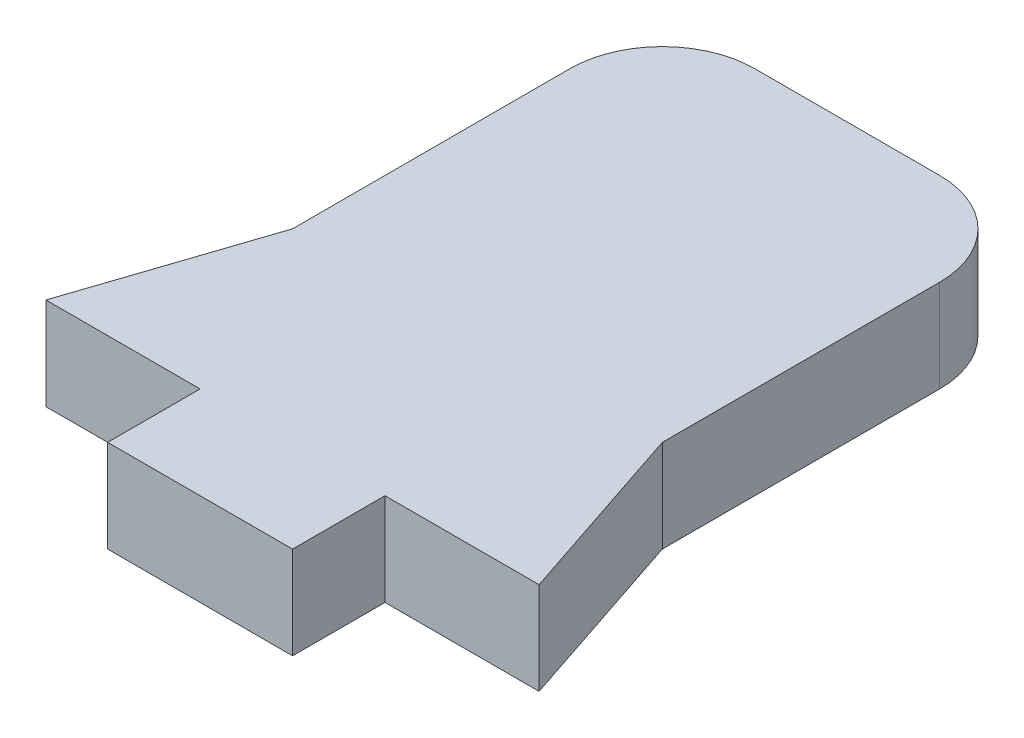
from build123d import *

# Parameters (mm, degrees)
BOSS_EXTRUDE4_DEPTH = 1.5
SKETCH8_W           = 6
SKETCH8_H           = 3
BOSS_EXTRUDE5_DEPTH = 1.5
BOSS_EXTRUDE6_DEPTH = 1.5


with BuildPart() as part:
    # Sketch6 → Boss-Extrude4 (new body, symmetric)
    with BuildSketch(Plane(origin=(0, 0, 0), x_dir=(1, 0, 0), z_dir=(0, 1, 0))):
        with BuildLine():
            Line((-3, 10.5), (3, 10.5))
            ThreePointArc((3, 10.5), (5.121320344, 9.621320344), (6, 7.5))
            Line((6, 7.5), (6, -7.5))
            Line((6, -7.5), (-6, -7.5))
            Line((-6, -7.5), (-6, 7.5))
            ThreePointArc((-6, 7.5), (-5.121320344, 9.621320344), (-3, 10.5))
        make_face()
    extrude(amount=BOSS_EXTRUDE4_DEPTH, both=True)

    # Sketch8 → Boss-Extrude5 (add, symmetric)
    with BuildSketch(Plane(origin=(0, 0, 0), x_dir=(1, 0, 0), z_dir=(0, 1, 0))):
        with Locations((0, -9)):
            Rectangle(SKETCH8_W, SKETCH8_H)
    extrude(amount=BOSS_EXTRUDE5_DEPTH, both=True)

    # Sketch9 → Boss-Extrude6 (add, symmetric)
    with BuildSketch(Plane(origin=(0, 0, 0), x_dir=(1, 0, 0), z_dir=(0, 1, 0))):
        Polygon((-6, -1.5), (-8, -7.5), (-6, -7.5), align=None)
        Polygon((6, -1.5), (6, -7.5), (8, -7.5), align=None)
    extrude(amount=BOSS_EXTRUDE6_DEPTH, both=True)


solid = part.part
